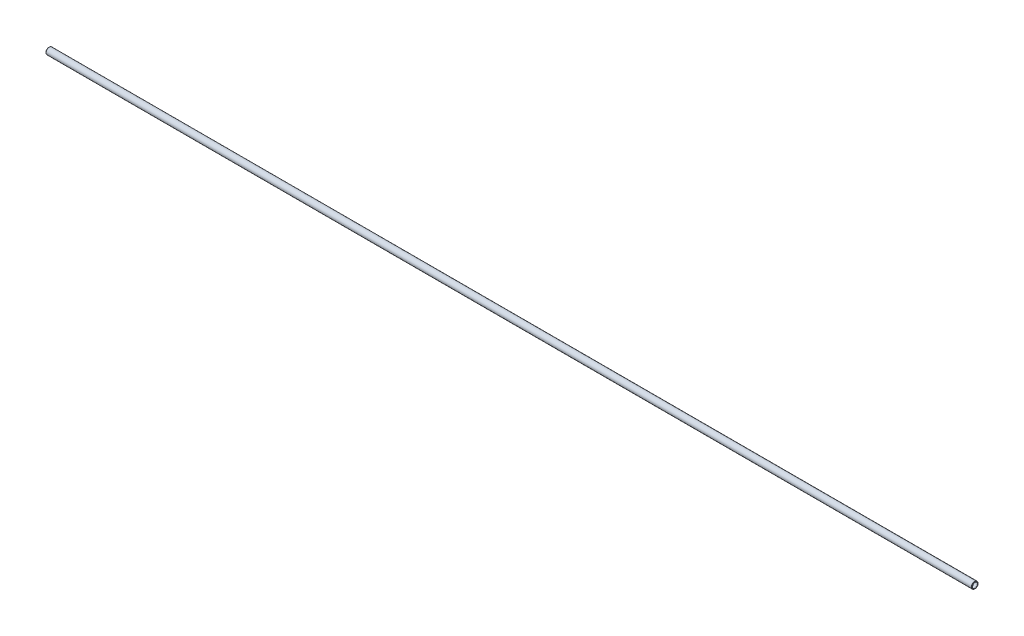
from build123d import *


with BuildPart() as part:
    # Sketch1 → Revolve1 (revolve)
    with BuildSketch(Plane.XY):
        with BuildLine():
            Line((-0.445028708, 3.689878708), (-0.2794, 3.52425))
            Line((-0.2794, 3.52425), (0, 3.52425))
            Line((0, 3.52425), (0.5588, 4.08305))
            Line((0.5588, 4.08305), (1288.2372, 4.08305))
            Line((1288.2372, 4.08305), (1288.796, 3.52425))
            Line((1288.796, 3.52425), (1289.0754, 3.52425))
            Line((1289.0754, 3.52425), (1289.241028708, 3.689878708))
            ThreePointArc((1289.241028708, 3.689878708), (1289.278226147, 3.779681269), (1289.241028708, 3.869483831))
            Line((1289.241028708, 3.869483831), (1288.714881269, 4.395631269))
            ThreePointArc((1288.714881269, 4.395631269), (1288.533593502, 4.516763883), (1288.31975, 4.5593))
            Line((1288.31975, 4.5593), (0.47625, 4.5593))
            ThreePointArc((0.47625, 4.5593), (0.262406498, 4.516763883), (0.081118731, 4.395631269))
            Line((0.081118731, 4.395631269), (-0.445028708, 3.869483831))
            ThreePointArc((-0.445028708, 3.869483831), (-0.482226147, 3.779681269), (-0.445028708, 3.689878708))
        make_face()
    revolve(axis=Axis((1288.796, 0, 0), (-1, 0, 0)))


solid = part.part
